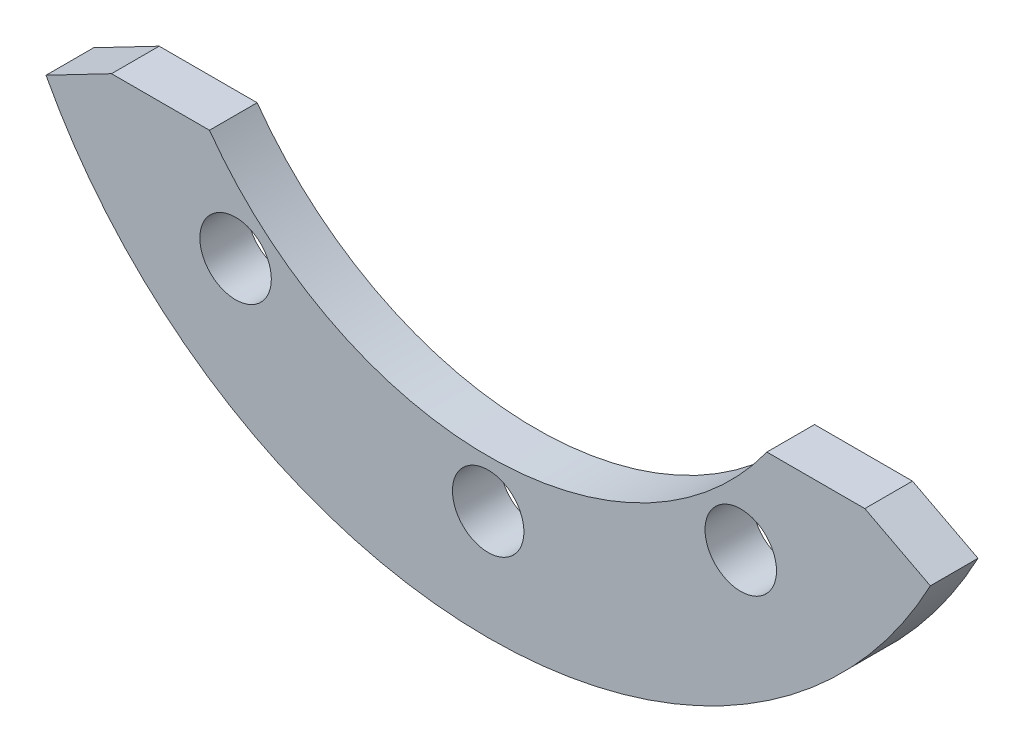
from build123d import *

# Parameters (mm, degrees)
BOSS_EXTRUDE1_DEPTH            = 1
F_1_5_1_5_DIAMETER_HOLE1_D     = 1.5
F_1_5_1_5_DIAMETER_HOLE1_DEPTH = 1
CUT_EXTRUDE2_DEPTH             = 2


with BuildPart() as part:
    # Sketch1 → Boss-Extrude1 (new body)
    with BuildSketch(Plane.XY):
        with BuildLine():
            Line((-9.623408959, -4.2), (-5.848076607, -4.2))
            ThreePointArc((-5.848076607, -4.2), (0, -7.2), (5.848076607, -4.2))
            Line((5.848076607, -4.2), (9.623408959, -4.2))
            ThreePointArc((9.623408959, -4.2), (0, -10.5), (-9.623408959, -4.2))
        make_face()
    extrude(amount=-BOSS_EXTRUDE1_DEPTH)

    # Ø1.5 (1.5) Diameter Hole1
    with Locations(Plane.XY):
        with Locations((0, -8.2), (-5.3, -6.256996084), (5.3, -6.256996084)):
            Hole(F_1_5_1_5_DIAMETER_HOLE1_D / 2, depth=F_1_5_1_5_DIAMETER_HOLE1_DEPTH)

    # Sketch2 → Cut-Extrude2 (cut, through all)
    with BuildSketch(Plane.XY):
        with BuildLine():
            Line((-7.903322086, -4.2), (-9.27823124, -4.915732403))
            ThreePointArc((-9.27823124, -4.915732403), (-9.457593181, -4.561132669), (-9.623408959, -4.2))
            Line((-9.623408959, -4.2), (-7.903322086, -4.2))
        make_face()
    cut_extrude2 = extrude(amount=-CUT_EXTRUDE2_DEPTH, mode=Mode.SUBTRACT)

    # Mirror1: Cut-Extrude2 across plane
    add(cut_extrude2.mirror(Plane(origin=(0, 0, 0), x_dir=(0, 0, 1), z_dir=(1, 0, 0))), mode=Mode.SUBTRACT)


solid = part.part
